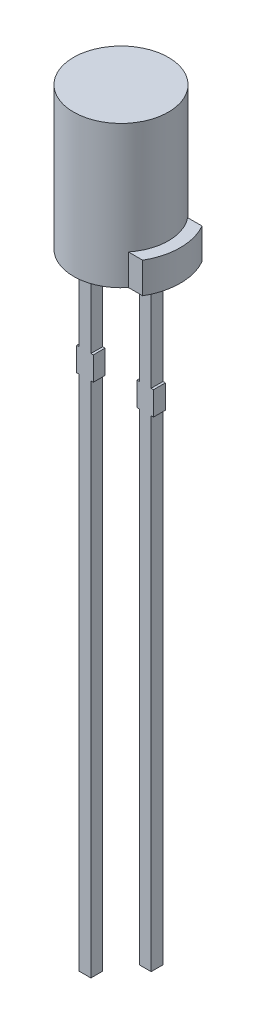
from build123d import *

# Parameters (mm, degrees)
SKETCH2_R          = 2
EXTRUDE2_DEPTH     = 6
SKETCH3_W          = 0.5
SKETCH3_H          = 4.2
SKETCH3_H_2        = 1
SKETCH3_H_3        = 21.8
SKETCH3_W_2        = 0.1
SKETCH3_H_4        = 20.3
EXTRUDE4_DEPTH     = 0.25
EXTRUDE5_DEPTH     = 1.3
CUT_EXTRUDE1_DEPTH = 0.01


with BuildPart() as part:
    # Sketch2 → Extrude2 (new body)
    with BuildSketch(Plane(origin=(0, 0, 0), x_dir=(1, 0, 0), z_dir=(0, 1, 0))):
        with Locations(Location((0, 0, 0), (0, 0, 270))):  # turned: the seam where the file's is
            Circle(SKETCH2_R)
    extrude(amount=EXTRUDE2_DEPTH)

    # Sketch3 → Extrude4 (add, symmetric)
    with BuildSketch(Plane.XY):
        with Locations((-1.27, -2.1)):
            Rectangle(SKETCH3_W, SKETCH3_H)
        with Locations((-1.27, -4.7)):
            Rectangle(SKETCH3_W, SKETCH3_H_2)
        with Locations((-1.27, -16.1)):
            Rectangle(SKETCH3_W, SKETCH3_H_3)
        with Locations((-0.97, -4.7)):
            Rectangle(SKETCH3_W_2, SKETCH3_H_2)
        with Locations((-1.57, -4.7)):
            Rectangle(SKETCH3_W_2, SKETCH3_H_2)
        with Locations((1.27, -2.1)):
            Rectangle(SKETCH3_W, SKETCH3_H)
        with Locations((1.27, -4.7)):
            Rectangle(SKETCH3_W, SKETCH3_H_2)
        with Locations((0.97, -4.7)):
            Rectangle(SKETCH3_W_2, SKETCH3_H_2)
        with Locations((1.57, -4.7)):
            Rectangle(SKETCH3_W_2, SKETCH3_H_2)
        with Locations((1.27, -15.35)):
            Rectangle(SKETCH3_W, SKETCH3_H_4)
    extrude(amount=EXTRUDE4_DEPTH, both=True)

    # Sketch2_4 → Extrude5 (add)
    with BuildSketch(Plane(origin=(0, 0, 0), x_dir=(1, 0, 0), z_dir=(0, 1, 0))):
        with BuildLine():
            ThreePointArc((2, 0), (1.887127314, -0.662382443), (1.5612495, -1.25))
            Line((1.5612495, -1.25), (2.165063509, -1.25))
            ThreePointArc((2.165063509, -1.25), (2.414814566, -0.647047613), (2.5, 0))
            ThreePointArc((2.5, 0), (2.414814566, 0.647047613), (2.165063509, 1.25))
            Line((2.165063509, 1.25), (1.5612495, 1.25))
            ThreePointArc((1.5612495, 1.25), (1.887127314, 0.662382443), (2, 0))
        make_face()
    extrude(amount=EXTRUDE5_DEPTH)

    # Sketch4 → Cut-Extrude1 (cut)
    with BuildSketch(Plane.XZ):
        Polygon((0.595738806, 1.083150286), (0.611739597, 1.159594115), (0.636996717, 1.161967533), (0.656874091, 1.113352027), (0.667020452, 1.164815634), (0.692613806, 1.167228609), (0.722459534, 1.095116267), (0.697459534, 1.092742849), (0.679916021, 1.142742849), (0.668879629, 1.090052976), (0.64777599, 1.088055349), (0.627859059, 1.137818008), (0.620204787, 1.08544459), align=None)
        Polygon((0.462167009, 1.070418429), (0.4781678, 1.146862258), (0.503424921, 1.149235676), (0.523302294, 1.10062017), (0.533448655, 1.152083777), (0.559042009, 1.154496752), (0.588887737, 1.08238441), (0.563887737, 1.080010993), (0.546344224, 1.130010993), (0.535307832, 1.077321119), (0.514204193, 1.075323493), (0.494287262, 1.125086151), (0.48663299, 1.072712733), align=None)
        Polygon((0.328595212, 1.057686572), (0.344596004, 1.134130401), (0.369853124, 1.136503819), (0.389730497, 1.087888313), (0.399876858, 1.13935192), (0.425470212, 1.141764895), (0.45531594, 1.069652553), (0.43031594, 1.067279136), (0.412772428, 1.117279136), (0.401736035, 1.064589262), (0.380632396, 1.062591636), (0.360715466, 1.112354294), (0.353061193, 1.059980876), align=None)
        Polygon((0.280862023, 1.127984779), (0.305585124, 1.13031864), (0.308037656, 1.104329716), (0.283314555, 1.101995855), align=None)
        with BuildLine():
            add(Edge.make_bspline(
                [(0.180076069, 1.08718491), (0.180000938, 1.088378037), (0.179853848, 1.090713918), (0.180129363, 1.094174057), (0.180772304, 1.09750651), (0.181856392, 1.100695423), (0.183302133, 1.103767609), (0.18521883, 1.106654646), (0.18748007, 1.109447891), (0.190155899, 1.11206351), (0.193175315, 1.114489277), (0.196515958, 1.116671544), (0.200162875, 1.118590066), (0.204091964, 1.120276489), (0.208348969, 1.121652526), (0.212888675, 1.122790391), (0.21773693, 1.123691997), (0.221080447, 1.12406052), (0.222797588, 1.124249783)],
                knots=[0, 0, 0, 0, 0.905522218, 1.772813168, 2.623814422, 3.472742767, 4.320212635, 5.190997638, 6.093561936, 7.040949947, 8.022337583, 9.026208329, 10.061623486, 11.143404926, 12.264251371, 13.450050967, 14.690414041, 16, 16, 16, 16], degree=3))
            add(Edge.make_bspline(
                [(0.222797588, 1.124249783), (0.224774175, 1.124417215), (0.228604197, 1.124741645), (0.234184017, 1.124846502), (0.239397228, 1.124699269), (0.244272845, 1.124176891), (0.248896938, 1.123460808), (0.253350833, 1.122554062), (0.257690232, 1.12155369), (0.260505957, 1.120711127), (0.261899645, 1.120294087)],
                knots=[0, 0, 0, 0, 1.202486756, 2.330052293, 3.38202457, 4.36253435, 5.30106619, 6.218328595, 7.118133652, 8, 8, 8, 8], degree=3))
            Line((0.261899645, 1.120294087), (0.264134613, 1.096678581))
            Line((0.264134613, 1.096678581), (0.261345847, 1.096401682))
            add(Edge.make_bspline(
                [(0.261345847, 1.096401682), (0.259917289, 1.097292344), (0.257064127, 1.099071203), (0.252499329, 1.101260048), (0.247738834, 1.10306299), (0.242832824, 1.104464353), (0.237909015, 1.105500935), (0.233059022, 1.106084672), (0.228340168, 1.106322757), (0.225249594, 1.106115915), (0.223727177, 1.106014024)],
                knots=[0, 0, 0, 0, 1.021706956, 2.040585956, 3.068229685, 4.109840531, 5.136110676, 6.120371821, 7.074095265, 8, 8, 8, 8], degree=3))
            add(Edge.make_bspline(
                [(0.223727177, 1.106014024), (0.223311342, 1.105971661), (0.222417695, 1.10588062), (0.220995596, 1.105650523), (0.219393538, 1.105373576), (0.217675381, 1.105055478), (0.21595584, 1.104675901), (0.21436053, 1.104231104), (0.212941274, 1.103715034), (0.21207531, 1.103316459), (0.211662303, 1.103126366)],
                knots=[0, 0, 0, 0, 0.804935788, 1.729844701, 2.773683006, 3.936767773, 5.095129051, 6.164379369, 7.124532199, 8, 8, 8, 8], degree=3))
            add(Edge.make_bspline(
                [(0.211662303, 1.103126366), (0.211210087, 1.102875996), (0.210338649, 1.102393524), (0.20912191, 1.101573972), (0.208071232, 1.100661203), (0.207113032, 1.09972013), (0.206334268, 1.098631764), (0.205896122, 1.097315735), (0.205670284, 1.095828554), (0.205734399, 1.094780476), (0.205768316, 1.094226049)],
                knots=[0, 0, 0, 0, 1.078489755, 2.078289828, 3.054234947, 3.978481303, 4.879078298, 5.81472297, 6.844001073, 8, 8, 8, 8], degree=3))
            add(Edge.make_bspline(
                [(0.205768316, 1.094226049), (0.20584868, 1.093704947), (0.206008065, 1.092671446), (0.206698321, 1.091229038), (0.207715875, 1.089948872), (0.209043641, 1.088802023), (0.210715637, 1.08786966), (0.212676562, 1.087080135), (0.214938325, 1.086447473), (0.216563904, 1.086191829), (0.217417841, 1.086057537)],
                knots=[0, 0, 0, 0, 0.819272605, 1.624862559, 2.460512002, 3.357803212, 4.344338068, 5.433444579, 6.651754585, 8, 8, 8, 8], degree=3))
            add(Edge.make_bspline(
                [(0.217417841, 1.086057537), (0.219361274, 1.085793675), (0.223340984, 1.085253345), (0.229382481, 1.084690325), (0.23541753, 1.084026649), (0.239350214, 1.08322508), (0.241270689, 1.082833644)],
                knots=[0, 0, 0, 0, 0.977169242, 2.001022012, 3.023825344, 4, 4, 4, 4], degree=3))
            add(Edge.make_bspline(
                [(0.241270689, 1.082833644), (0.242308421, 1.082586798), (0.244324322, 1.082107275), (0.247219826, 1.081238479), (0.249902679, 1.08024935), (0.252373636, 1.079144719), (0.254645691, 1.077936669), (0.256710312, 1.076616114), (0.258555413, 1.075169128), (0.260196383, 1.073611153), (0.261647083, 1.07193739), (0.262938308, 1.070150628), (0.264069747, 1.068243844), (0.265038785, 1.066217551), (0.265858503, 1.06407731), (0.266477786, 1.061801155), (0.266988538, 1.059419702), (0.267168428, 1.057776531), (0.267259613, 1.056943613)],
                knots=[0, 0, 0, 0, 1.286961518, 2.500053848, 3.645331982, 4.734993694, 5.763585052, 6.747778267, 7.688337644, 8.588673112, 9.474016412, 10.357212555, 11.245410657, 12.145640677, 13.064656499, 14.006627877, 14.989566337, 16, 16, 16, 16], degree=3))
            add(Edge.make_bspline(
                [(0.267259613, 1.056943613), (0.267324594, 1.055816697), (0.267452431, 1.053599709), (0.267204619, 1.050309014), (0.266483677, 1.047154778), (0.265430191, 1.044103412), (0.263911642, 1.041204275), (0.262045189, 1.038398113), (0.259721017, 1.035761505), (0.25706498, 1.033230857), (0.254061639, 1.030921484), (0.250812211, 1.028814776), (0.247310428, 1.026969486), (0.243557681, 1.025385406), (0.239550974, 1.024071042), (0.235310655, 1.022981477), (0.230822796, 1.022147227), (0.227738257, 1.021797961), (0.22615993, 1.021619245)],
                knots=[0, 0, 0, 0, 0.896646048, 1.763978263, 2.612019967, 3.462260768, 4.322391784, 5.206065637, 6.134830007, 7.109712514, 8.118089394, 9.141388381, 10.184527878, 11.260019642, 12.375272374, 13.533145802, 14.737735533, 16, 16, 16, 16], degree=3))
            add(Edge.make_bspline(
                [(0.22615993, 1.021619245), (0.224545593, 1.021489847), (0.221320456, 1.021231333), (0.216468108, 1.021154677), (0.211616101, 1.02125482), (0.206819112, 1.021640639), (0.202182402, 1.022209983), (0.197799089, 1.022916349), (0.193719224, 1.023764537), (0.191135007, 1.024505061), (0.189886196, 1.024862916)],
                knots=[0, 0, 0, 0, 1.060995351, 2.119666118, 3.178433844, 4.240062289, 5.271587711, 6.238937603, 7.148974324, 8, 8, 8, 8], degree=3))
            Line((0.189886196, 1.024862916), (0.18775012, 1.047548834))
            Line((0.18775012, 1.047548834), (0.190459771, 1.047805954))
            add(Edge.make_bspline(
                [(0.190459771, 1.047805954), (0.191568298, 1.047117926), (0.193832759, 1.045712444), (0.197541182, 1.043982127), (0.201532726, 1.042423399), (0.20579817, 1.041143403), (0.210228115, 1.040139996), (0.214731312, 1.039579525), (0.219239836, 1.039375158), (0.222231203, 1.039576372), (0.223727177, 1.039676999)],
                knots=[0, 0, 0, 0, 0.897762896, 1.833920623, 2.812788637, 3.846900937, 4.897780298, 5.936764651, 6.968182516, 8, 8, 8, 8], degree=3))
            add(Edge.make_bspline(
                [(0.223727177, 1.039676999), (0.224777359, 1.039802953), (0.226881861, 1.040055357), (0.229997825, 1.040658599), (0.233051122, 1.041528956), (0.234946046, 1.042444406), (0.235890942, 1.042900891)],
                knots=[0, 0, 0, 0, 1.002284203, 2.008515686, 3.006954358, 4, 4, 4, 4], degree=3))
            add(Edge.make_bspline(
                [(0.235890942, 1.042900891), (0.23629072, 1.043117546), (0.237089435, 1.043550401), (0.238206516, 1.044330643), (0.239166674, 1.045290227), (0.240070589, 1.046291219), (0.240772178, 1.047416056), (0.241296483, 1.048587502), (0.24151249, 1.049835654), (0.241483302, 1.050666905), (0.241468474, 1.051089182)],
                knots=[0, 0, 0, 0, 1.037193998, 2.072204887, 3.093354871, 4.127600583, 5.141526014, 6.105240849, 7.037459425, 8, 8, 8, 8], degree=3))
            add(Edge.make_bspline(
                [(0.241468474, 1.051089182), (0.241380153, 1.051703821), (0.241210038, 1.052887671), (0.24046405, 1.054494124), (0.239391399, 1.055857771), (0.238169782, 1.056704923), (0.237016987, 1.057274584), (0.235971869, 1.057685858), (0.234758403, 1.058053507), (0.233392041, 1.058407021), (0.231863692, 1.058749275), (0.230164681, 1.059032004), (0.228300648, 1.059319217), (0.22699791, 1.059460746), (0.226318158, 1.059534594)],
                knots=[0, 0, 0, 0, 1.171426997, 2.25627642, 3.314014895, 4.423837728, 5.038558498, 5.750938772, 6.549313359, 7.440391281, 8.425752722, 9.516630727, 10.704208796, 12, 12, 12, 12], degree=3))
            add(Edge.make_bspline(
                [(0.226318158, 1.059534594), (0.224512168, 1.059743208), (0.220973241, 1.060151999), (0.215652889, 1.060692407), (0.210229219, 1.061455286), (0.206581538, 1.062233985), (0.204680499, 1.062639815)],
                knots=[0, 0, 0, 0, 0.997345898, 1.954349026, 2.933880906, 4, 4, 4, 4], degree=3))
            add(Edge.make_bspline(
                [(0.204680499, 1.062639815), (0.203735086, 1.06286721), (0.201891253, 1.063310696), (0.19923753, 1.064125651), (0.196759615, 1.06503224), (0.194457787, 1.066037971), (0.192333478, 1.067153691), (0.190364632, 1.068343753), (0.188608139, 1.069683431), (0.186994749, 1.071092835), (0.185574052, 1.072645801), (0.1842916, 1.074309465), (0.183201032, 1.076135528), (0.182260621, 1.078083423), (0.181455584, 1.080164174), (0.180831803, 1.08238369), (0.180351856, 1.084737379), (0.180169136, 1.086358965), (0.180076069, 1.08718491)],
                knots=[0, 0, 0, 0, 1.23764655, 2.413774307, 3.531682084, 4.595210585, 5.608818858, 6.584790941, 7.519772016, 8.417508597, 9.308431962, 10.194757595, 11.087181963, 12.010602069, 12.945809139, 13.923439875, 14.9423162, 16, 16, 16, 16], degree=3))
        make_face()
        with BuildLine():
            Line((0.086271392, 1.109482974), (0.110084683, 1.111737721))
            Line((0.110084683, 1.111737721), (0.110856044, 1.103529651))
            add(Edge.make_bspline(
                [(0.110856044, 1.103529651), (0.111849622, 1.104429509), (0.113767546, 1.106166521), (0.11667667, 1.108517729), (0.119466318, 1.110561117), (0.122183333, 1.112344803), (0.125011892, 1.113825056), (0.128111342, 1.114915407), (0.131491185, 1.115738487), (0.133860768, 1.116021778), (0.135084683, 1.116168101)],
                knots=[0, 0, 0, 0, 1.152164645, 2.224045628, 3.213659577, 4.123879723, 5.016101453, 5.950129621, 6.941219263, 8, 8, 8, 8], degree=3))
            add(Edge.make_bspline(
                [(0.135084683, 1.116168101), (0.136086192, 1.116246892), (0.138028632, 1.116399708), (0.140880931, 1.116302044), (0.143576357, 1.116020267), (0.146125992, 1.115491624), (0.148514198, 1.114697319), (0.150740579, 1.113653476), (0.152840016, 1.11241954), (0.154737082, 1.110890425), (0.156497127, 1.109173054), (0.158042647, 1.107188703), (0.15941065, 1.104988595), (0.160576651, 1.102550543), (0.161570406, 1.099891588), (0.162343791, 1.096994045), (0.16297248, 1.093877457), (0.163207296, 1.091711281), (0.163328354, 1.090594525)],
                knots=[0, 0, 0, 0, 1.108114918, 2.149202164, 3.14494175, 4.096957924, 5.01749491, 5.91613894, 6.807266765, 7.698335156, 8.598892543, 9.516115384, 10.467268884, 11.453495497, 12.494353796, 13.596021602, 14.76064642, 16, 16, 16, 16], degree=3))
            Line((0.163328354, 1.090594525), (0.167897183, 1.042255917))
            Line((0.167897183, 1.042255917), (0.143945443, 1.04000117))
            Line((0.143945443, 1.04000117), (0.14046443, 1.076828702))
            add(Edge.make_bspline(
                [(0.14046443, 1.076828702), (0.140374833, 1.077725591), (0.140203381, 1.079441862), (0.139915149, 1.081897121), (0.139575212, 1.084105018), (0.139228687, 1.086088659), (0.138811258, 1.087866475), (0.13833112, 1.089476396), (0.137724474, 1.090913223), (0.137210636, 1.091766596), (0.136963639, 1.092176803)],
                knots=[0, 0, 0, 0, 1.362599764, 2.607448668, 3.736476168, 4.739330694, 5.650702323, 6.495560924, 7.276831317, 8, 8, 8, 8], degree=3))
            add(Edge.make_bspline(
                [(0.136963639, 1.092176803), (0.136696476, 1.092540527), (0.136169677, 1.093257726), (0.13520928, 1.094198473), (0.13406344, 1.094897705), (0.132782392, 1.095455571), (0.131303082, 1.095799624), (0.129605328, 1.095986883), (0.127671488, 1.096027069), (0.126309056, 1.09591478), (0.125591012, 1.095855601)],
                knots=[0, 0, 0, 0, 0.856644385, 1.689153085, 2.533351611, 3.391641808, 4.333134902, 5.404855211, 6.632277889, 8, 8, 8, 8], degree=3))
            add(Edge.make_bspline(
                [(0.125591012, 1.095855601), (0.125068378, 1.095793375), (0.123994211, 1.095665484), (0.12236668, 1.095265521), (0.12066363, 1.094760329), (0.118313678, 1.093845691), (0.115353605, 1.09243765), (0.11320849, 1.09089917), (0.112121867, 1.090119841)],
                knots=[0, 0, 0, 0, 0.639166514, 1.313674521, 2.03363351, 2.797097134, 4.377547342, 6, 6, 6, 6], degree=3))
            Line((0.112121867, 1.090119841), (0.117106044, 1.037469525))
            Line((0.117106044, 1.037469525), (0.093292753, 1.035214778))
            Line((0.093292753, 1.035214778), (0.086271392, 1.109482974))
        make_face()
        with BuildLine():
            Line((-0.011350532, 1.100175026), (0.01258143, 1.102429773))
            Line((0.01258143, 1.102429773), (0.016062443, 1.065602241))
            add(Edge.make_bspline(
                [(0.016062443, 1.065602241), (0.016224024, 1.064103453), (0.016546316, 1.061113945), (0.017185987, 1.057457291), (0.017794896, 1.05470606), (0.018328449, 1.052950313), (0.018882429, 1.051471907), (0.019362029, 1.050638258), (0.019583013, 1.05025414)],
                knots=[0, 0, 0, 0, 1.711554294, 3.413896861, 4.213021049, 4.90936265, 5.497470356, 6, 6, 6, 6], degree=3))
            add(Edge.make_bspline(
                [(0.019583013, 1.05025414), (0.019855509, 1.049888664), (0.020396209, 1.049163471), (0.021392697, 1.048251912), (0.022528125, 1.047519741), (0.023820337, 1.046983003), (0.025300702, 1.046623817), (0.027002585, 1.046472656), (0.028934142, 1.046421008), (0.030296807, 1.046535029), (0.031014975, 1.046595121)],
                knots=[0, 0, 0, 0, 0.861634224, 1.709689945, 2.540671462, 3.407713485, 4.346206362, 5.41312505, 6.636636352, 8, 8, 8, 8], degree=3))
            add(Edge.make_bspline(
                [(0.031014975, 1.046595121), (0.03210339, 1.046753268), (0.034322261, 1.047075672), (0.037026563, 1.048008434), (0.039195133, 1.04902622), (0.040884187, 1.049990206), (0.042657828, 1.051064798), (0.043810812, 1.051900301), (0.044405006, 1.05233088)],
                knots=[0, 0, 0, 0, 1.340233279, 2.732231585, 3.470218484, 4.262786462, 5.104721098, 6, 6, 6, 6], degree=3))
            Line((0.044405006, 1.05233088), (0.039440607, 1.104981197))
            Line((0.039440607, 1.104981197), (0.063253899, 1.107216165))
            Line((0.063253899, 1.107216165), (0.070275259, 1.032947969))
            Line((0.070275259, 1.032947969), (0.046461968, 1.030713001))
            Line((0.046461968, 1.030713001), (0.045690607, 1.03892107))
            add(Edge.make_bspline(
                [(0.045690607, 1.03892107), (0.044722801, 1.038035385), (0.042838874, 1.036311314), (0.039958292, 1.033942193), (0.037077509, 1.031917839), (0.034253361, 1.030104467), (0.031319652, 1.028628499), (0.028212176, 1.027504893), (0.024911204, 1.026677811), (0.022626515, 1.026402946), (0.021461968, 1.026262842)],
                knots=[0, 0, 0, 0, 1.128280691, 2.196305633, 3.204826773, 4.155092717, 5.080676663, 6.022445781, 6.992005032, 8, 8, 8, 8], degree=3))
            add(Edge.make_bspline(
                [(0.021461968, 1.026262842), (0.02048028, 1.026195666), (0.018570738, 1.026064997), (0.015762651, 1.026113586), (0.013103429, 1.026439647), (0.01058162, 1.026960838), (0.008206562, 1.027737477), (0.005983167, 1.02875503), (0.003882723, 1.029984284), (0.001941321, 1.031470597), (0.000178933, 1.033205442), (-0.001426435, 1.035155596), (-0.002799843, 1.037365119), (-0.004001568, 1.039800062), (-0.004971709, 1.042479431), (-0.005792132, 1.045385243), (-0.006396241, 1.048529928), (-0.006650817, 1.05071368), (-0.006781703, 1.051836418)],
                knots=[0, 0, 0, 0, 1.0872505, 2.114877859, 3.098202874, 4.044268561, 4.956739394, 5.853451236, 6.741954745, 7.641149904, 8.54801769, 9.469808848, 10.426006009, 11.41664689, 12.465622852, 13.570601432, 14.750967542, 16, 16, 16, 16], degree=3))
            Line((-0.006781703, 1.051836418), (-0.011350532, 1.100175026))
        make_face()
        Polygon((-0.106144133, 1.091143976), (-0.035099829, 1.097848881), (-0.025803943, 0.999371824), (-0.051199513, 0.996978628), (-0.058695557, 1.076409008), (-0.104344291, 1.072097299), align=None)
        Polygon((-0.193289597, 1.082836479), (-0.122047508, 1.089561163), (-0.112751622, 0.991084106), (-0.183993711, 0.984359423), (-0.185793552, 1.0034061), (-0.139828362, 1.007737587), (-0.141430419, 1.024727302), (-0.184072824, 1.020712271), (-0.185872666, 1.039758948), (-0.143230261, 1.043773979), (-0.145524565, 1.06812129), (-0.191489755, 1.063789802), align=None)
        with BuildLine():
            add(Edge.make_bspline(
                [(-0.303705554, 1.022761493), (-0.303792129, 1.023894809), (-0.303963094, 1.026132847), (-0.303972821, 1.029468777), (-0.303806975, 1.032733321), (-0.30340296, 1.035929993), (-0.302811858, 1.039055184), (-0.302025455, 1.042112375), (-0.301005518, 1.045088017), (-0.299804382, 1.047978918), (-0.298442762, 1.050766146), (-0.296937442, 1.053406734), (-0.295335538, 1.055920588), (-0.293593073, 1.058263776), (-0.291753775, 1.06047237), (-0.289783343, 1.062519998), (-0.287690839, 1.064418614), (-0.286208868, 1.065577522), (-0.285469794, 1.066155481)],
                knots=[0, 0, 0, 0, 1.108752944, 2.189532157, 3.252570796, 4.296260022, 5.330849015, 6.354419021, 7.373633347, 8.397486336, 9.407338928, 10.398369786, 11.361982234, 12.314102121, 13.245680119, 14.164735136, 15.084735289, 16, 16, 16, 16], degree=3))
            add(Edge.make_bspline(
                [(-0.285469794, 1.066155481), (-0.2843176, 1.06696977), (-0.282007793, 1.068602178), (-0.278268378, 1.07063659), (-0.274352835, 1.072400327), (-0.270180231, 1.073821532), (-0.265704801, 1.075014233), (-0.260844852, 1.075978994), (-0.255582699, 1.076827322), (-0.251921345, 1.0771979), (-0.250026756, 1.077389658)],
                knots=[0, 0, 0, 0, 0.898226624, 1.800676254, 2.706959409, 3.631504289, 4.605561171, 5.655869771, 6.787016565, 8, 8, 8, 8], degree=3))
            Line((-0.250026756, 1.077389658), (-0.215295744, 1.080672886))
            Line((-0.215295744, 1.080672886), (-0.205999857, 0.982195829))
            Line((-0.205999857, 0.982195829), (-0.241719794, 0.978813708))
            add(Edge.make_bspline(
                [(-0.241719794, 0.978813708), (-0.243663561, 0.978657033), (-0.247408755, 0.978355154), (-0.252855343, 0.978211823), (-0.257908459, 0.978355789), (-0.262588096, 0.978802824), (-0.266892165, 0.979544215), (-0.270871126, 0.980480265), (-0.27453305, 0.98166909), (-0.276795456, 0.982702469), (-0.277894636, 0.983204531)],
                knots=[0, 0, 0, 0, 1.268673849, 2.444444452, 3.543152422, 4.556056618, 5.500363377, 6.382673113, 7.214228933, 8, 8, 8, 8], degree=3))
            add(Edge.make_bspline(
                [(-0.277894636, 0.983204531), (-0.278778193, 0.983653836), (-0.280537922, 0.98454869), (-0.283043061, 0.986099536), (-0.285433159, 0.98779185), (-0.287703789, 0.989623553), (-0.289844191, 0.991612703), (-0.291872437, 0.993733605), (-0.293771489, 0.996015954), (-0.295552346, 0.998440178), (-0.297173431, 1.001020091), (-0.298642889, 1.003721848), (-0.299906373, 1.006572259), (-0.301014752, 1.009544723), (-0.301968088, 1.01265352), (-0.302734447, 1.015904619), (-0.303334277, 1.019285587), (-0.303580714, 1.021592739), (-0.303705554, 1.022761493)],
                knots=[0, 0, 0, 0, 0.961009519, 1.913987343, 2.854267442, 3.799945452, 4.741073053, 5.686297007, 6.644153152, 7.618681425, 8.601460506, 9.597072869, 10.598825991, 11.622600514, 12.672342922, 13.750217676, 14.860307228, 16, 16, 16, 16], degree=3))
        make_face()
        with BuildLine():
            add(Edge.make_bspline(
                [(-0.277439731, 1.025036019), (-0.277259987, 1.023473422), (-0.276912118, 1.020449237), (-0.275786631, 1.016154582), (-0.274356666, 1.012218874), (-0.272744075, 1.009262645), (-0.271252181, 1.007121952), (-0.270019286, 1.005636341), (-0.268676983, 1.004238569), (-0.267182073, 1.002984642), (-0.265592739, 1.0018004), (-0.263875219, 1.000743418), (-0.262040313, 0.99977832), (-0.260751229, 0.999241614), (-0.260094003, 0.998967981)],
                knots=[0, 0, 0, 0, 1.705404723, 3.300570454, 4.806618999, 6.241382947, 6.940248714, 7.636655035, 8.335080941, 9.040693201, 9.752088672, 10.484904539, 11.227544252, 12, 12, 12, 12], degree=3))
            add(Edge.make_bspline(
                [(-0.260094003, 0.998967981), (-0.258739814, 0.998520176), (-0.256066773, 0.997636253), (-0.252503261, 0.997091439), (-0.249400572, 0.997005927), (-0.246570281, 0.99708308), (-0.243232206, 0.997256616), (-0.240842341, 0.997469571), (-0.23956394, 0.997583487)],
                knots=[0, 0, 0, 0, 1.234151206, 2.436098757, 3.104722821, 3.921632553, 4.888226682, 6, 6, 6, 6], degree=3))
            Line((-0.23956394, 0.997583487), (-0.233135933, 0.99819662))
            Line((-0.233135933, 0.99819662), (-0.238950807, 1.059826367))
            Line((-0.238950807, 1.059826367), (-0.245378813, 1.059213234))
            add(Edge.make_bspline(
                [(-0.245378813, 1.059213234), (-0.24611101, 1.059144328), (-0.247517373, 1.059011977), (-0.249552496, 1.058761781), (-0.251434172, 1.058537835), (-0.253168361, 1.05827812), (-0.254736755, 1.058001756), (-0.256162814, 1.05772579), (-0.257428978, 1.057433769), (-0.258923036, 1.057037555), (-0.260667701, 1.056450563), (-0.26268502, 1.055571273), (-0.264672367, 1.05454721), (-0.265940938, 1.053744336), (-0.266581345, 1.053339025)],
                knots=[0, 0, 0, 0, 1.189098597, 2.283956679, 3.31531765, 4.253067775, 5.118858824, 5.890319965, 6.601456144, 7.21948254, 8.389262148, 9.573476576, 10.775029794, 12, 12, 12, 12], degree=3))
            add(Edge.make_bspline(
                [(-0.266581345, 1.053339025), (-0.267116183, 1.052952686), (-0.268170255, 1.052191281), (-0.269606691, 1.050901401), (-0.270973292, 1.049590859), (-0.272166574, 1.048154483), (-0.273264618, 1.046677409), (-0.274219642, 1.045110126), (-0.275070532, 1.043482574), (-0.276030696, 1.041168033), (-0.276950919, 1.038054106), (-0.277563435, 1.034011903), (-0.27776383, 1.029628426), (-0.277550407, 1.02660428), (-0.277439731, 1.025036019)],
                knots=[0, 0, 0, 0, 0.742914295, 1.464153614, 2.173354713, 2.874415501, 3.565365736, 4.245771409, 4.94022741, 5.632853065, 7.0666969, 8.586097399, 10.229617933, 12, 12, 12, 12], degree=3))
        make_face(mode=Mode.SUBTRACT)
        Polygon((-0.352973956, 1.067568515), (-0.328250855, 1.069902375), (-0.325798323, 1.043913451), (-0.350521424, 1.041579591), align=None)
        with BuildLine():
            add(Edge.make_bspline(
                [(-0.415409435, 1.063615956), (-0.413821645, 1.063743708), (-0.410708716, 1.06399417), (-0.406107699, 1.063984904), (-0.401691325, 1.063678512), (-0.397463956, 1.063048312), (-0.393445018, 1.062104384), (-0.389632506, 1.060843053), (-0.386061328, 1.059211003), (-0.383862792, 1.057844384), (-0.382774942, 1.057168171)],
                knots=[0, 0, 0, 0, 1.12675004, 2.209039731, 3.2520183, 4.256823248, 5.229940226, 6.169653809, 7.094332871, 8, 8, 8, 8], degree=3))
            add(Edge.make_bspline(
                [(-0.382774942, 1.057168171), (-0.381746646, 1.056420894), (-0.379691413, 1.054927327), (-0.376949317, 1.052242825), (-0.374528801, 1.049211341), (-0.372402954, 1.045853971), (-0.370603816, 1.042145694), (-0.369218376, 1.038070867), (-0.368172328, 1.033652714), (-0.367810844, 1.030571252), (-0.367624625, 1.028983836)],
                knots=[0, 0, 0, 0, 0.920615294, 1.840013812, 2.771606673, 3.727671218, 4.715306354, 5.752253409, 6.842072703, 8, 8, 8, 8], degree=3))
            add(Edge.make_bspline(
                [(-0.367624625, 1.028983836), (-0.367503718, 1.027303468), (-0.367269989, 1.02405512), (-0.367504426, 1.019309096), (-0.368150074, 1.014871622), (-0.369313023, 1.010747488), (-0.370882652, 1.006929088), (-0.372829179, 1.00339764), (-0.375171847, 1.00016223), (-0.37700921, 0.998254132), (-0.377929214, 0.997298709)],
                knots=[0, 0, 0, 0, 1.170245432, 2.262222357, 3.296097347, 4.281367261, 5.232928986, 6.160206927, 7.078779014, 8, 8, 8, 8], degree=3))
            add(Edge.make_bspline(
                [(-0.377929214, 0.997298709), (-0.378881455, 0.996453535), (-0.380798741, 0.994751823), (-0.384007463, 0.992567023), (-0.387467862, 0.990662357), (-0.391158068, 0.989047666), (-0.395032097, 0.98774392), (-0.399018604, 0.986664051), (-0.403112001, 0.985870922), (-0.405886857, 0.985552158), (-0.40728048, 0.985392064)],
                knots=[0, 0, 0, 0, 0.946906943, 1.90654564, 2.88174188, 3.883744891, 4.900207498, 5.921538793, 6.956129209, 8, 8, 8, 8], degree=3))
            add(Edge.make_bspline(
                [(-0.40728048, 0.985392064), (-0.408525798, 0.98530021), (-0.410967975, 0.985120078), (-0.414581695, 0.985071194), (-0.418068467, 0.985278659), (-0.421438341, 0.985665753), (-0.424682581, 0.986269648), (-0.427824505, 0.987016797), (-0.430887767, 0.987836636), (-0.43286488, 0.988543273), (-0.43384298, 0.988892855)],
                knots=[0, 0, 0, 0, 1.10896075, 2.174767254, 3.207037272, 4.209376132, 5.185650549, 6.135885339, 7.077802142, 8, 8, 8, 8], degree=3))
            Line((-0.43384298, 0.988892855), (-0.435761492, 1.009205355))
            Line((-0.435761492, 1.009205355), (-0.432379372, 1.00952181))
            add(Edge.make_bspline(
                [(-0.432379372, 1.00952181), (-0.431824967, 1.009140287), (-0.430625807, 1.008315064), (-0.428702697, 1.006962659), (-0.426384606, 1.005573976), (-0.424629948, 1.004807098), (-0.423696619, 1.004399184)],
                knots=[0, 0, 0, 0, 0.799084726, 1.728394909, 2.791698194, 4, 4, 4, 4], degree=3))
            add(Edge.make_bspline(
                [(-0.423696619, 1.004399184), (-0.422713951, 1.004031124), (-0.420700577, 1.003277011), (-0.418037446, 1.002615911), (-0.415759491, 1.00227783), (-0.41390242, 1.00213879), (-0.411932111, 1.002138347), (-0.410582997, 1.002246969), (-0.409891239, 1.002302665)],
                knots=[0, 0, 0, 0, 1.337990229, 2.741389548, 3.489534986, 4.273912528, 5.114950199, 6, 6, 6, 6], degree=3))
            add(Edge.make_bspline(
                [(-0.409891239, 1.002302665), (-0.409117176, 1.002392353), (-0.407616463, 1.002566236), (-0.405463873, 1.00308162), (-0.403449799, 1.003713485), (-0.401609645, 1.004579869), (-0.399899974, 1.005581985), (-0.398380326, 1.006810573), (-0.396977556, 1.008168709), (-0.395771333, 1.009730336), (-0.394730728, 1.011433917), (-0.393827069, 1.01325337), (-0.393144057, 1.015211688), (-0.392611415, 1.01727585), (-0.392224626, 1.019457038), (-0.392067851, 1.021761587), (-0.392034161, 1.024180657), (-0.392163019, 1.025826364), (-0.392229056, 1.026669753)],
                knots=[0, 0, 0, 0, 1.094995874, 2.122921033, 3.108179543, 4.058251519, 4.977412549, 5.888304534, 6.799715531, 7.717893827, 8.654613687, 9.604278324, 10.56921186, 11.565534943, 12.600628658, 13.679487035, 14.81078666, 16, 16, 16, 16], degree=3))
            add(Edge.make_bspline(
                [(-0.392229056, 1.026669753), (-0.392329192, 1.027535187), (-0.392523581, 1.029215213), (-0.393003494, 1.031633699), (-0.393606646, 1.033881051), (-0.394378552, 1.035948814), (-0.395307529, 1.037841167), (-0.396400799, 1.039548882), (-0.39763151, 1.041083687), (-0.399004238, 1.042439637), (-0.400515404, 1.043608259), (-0.402151243, 1.044608995), (-0.403911094, 1.045415873), (-0.405793675, 1.046039487), (-0.407793583, 1.046442388), (-0.409910872, 1.046678228), (-0.412148517, 1.046745437), (-0.413676033, 1.04662746), (-0.414460068, 1.046566905)],
                knots=[0, 0, 0, 0, 1.228965952, 2.385735588, 3.475863361, 4.50921211, 5.495285741, 6.445008473, 7.364729435, 8.266008481, 9.16112025, 10.054635116, 10.966274306, 11.887123876, 12.846864245, 13.839324827, 14.89098052, 16, 16, 16, 16], degree=3))
            add(Edge.make_bspline(
                [(-0.414460068, 1.046566905), (-0.41518619, 1.046481576), (-0.416611046, 1.046314134), (-0.418684421, 1.045950642), (-0.420633733, 1.045432943), (-0.42244139, 1.044792902), (-0.424116188, 1.044114745), (-0.425624299, 1.043367541), (-0.427000698, 1.042634455), (-0.427828085, 1.042071135), (-0.428225891, 1.041800291)],
                knots=[0, 0, 0, 0, 1.191442946, 2.337950479, 3.427351757, 4.47394677, 5.461634542, 6.369857425, 7.216231234, 8, 8, 8, 8], degree=3))
            add(Edge.make_bspline(
                [(-0.428225891, 1.041800291), (-0.428902417, 1.041292297), (-0.430206104, 1.040313376), (-0.431920334, 1.038690404), (-0.433430278, 1.037087289), (-0.434372785, 1.036027153), (-0.434831904, 1.035510735)],
                knots=[0, 0, 0, 0, 1.109595254, 2.138223272, 3.093083025, 4, 4, 4, 4], degree=3))
            Line((-0.434831904, 1.035510735), (-0.438214024, 1.035194279))
            Line((-0.438214024, 1.035194279), (-0.440132537, 1.055487))
            add(Edge.make_bspline(
                [(-0.440132537, 1.055487), (-0.439234147, 1.056003423), (-0.437428192, 1.057041541), (-0.434630675, 1.058439562), (-0.431744858, 1.059681032), (-0.42878687, 1.060830757), (-0.425681131, 1.061798658), (-0.422421927, 1.062613448), (-0.418978408, 1.06322962), (-0.416617804, 1.063485152), (-0.415409435, 1.063615956)],
                knots=[0, 0, 0, 0, 0.947330783, 1.904335564, 2.857326213, 3.81897093, 4.804630844, 5.829491346, 6.888939505, 8, 8, 8, 8], degree=3))
        make_face()
        with BuildLine():
            add(Edge.make_bspline(
                [(-0.529600862, 1.013345728), (-0.529714174, 1.014834831), (-0.529935648, 1.017745347), (-0.529796706, 1.022020984), (-0.529355075, 1.026093055), (-0.528550095, 1.029951723), (-0.527380947, 1.033609894), (-0.525826463, 1.037038312), (-0.523942168, 1.040268924), (-0.521693472, 1.043262679), (-0.5191301, 1.046011958), (-0.516240559, 1.048468407), (-0.513024654, 1.05058149), (-0.509539205, 1.052427683), (-0.505748685, 1.053959183), (-0.501651016, 1.055152086), (-0.497259165, 1.056068777), (-0.494214199, 1.056420912), (-0.492654659, 1.056601266)],
                knots=[0, 0, 0, 0, 1.11005242, 2.169645169, 3.176323611, 4.153438899, 5.096288594, 6.026855042, 6.947758942, 7.872584178, 8.805834089, 9.738220459, 10.686157051, 11.662275176, 12.667567271, 13.721072089, 14.832802022, 16, 16, 16, 16], degree=3))
            add(Edge.make_bspline(
                [(-0.492654659, 1.056601266), (-0.491086559, 1.056718863), (-0.48803176, 1.056947953), (-0.483545464, 1.056861727), (-0.479295929, 1.056437156), (-0.475279057, 1.055651718), (-0.471505218, 1.054496497), (-0.467954944, 1.053024369), (-0.46466722, 1.051138101), (-0.461628044, 1.048924658), (-0.458841121, 1.046411444), (-0.456385574, 1.043586356), (-0.454234089, 1.04049446), (-0.45238672, 1.037135579), (-0.450862174, 1.033494259), (-0.449663916, 1.029584055), (-0.448762922, 1.025401058), (-0.4484254, 1.022506899), (-0.448251969, 1.021019778)],
                knots=[0, 0, 0, 0, 1.168859581, 2.277043282, 3.331750654, 4.34132596, 5.315274156, 6.262256999, 7.193266664, 8.126841649, 9.053555677, 9.977815379, 10.904010515, 11.849736107, 12.823116512, 13.83419064, 14.887130329, 16, 16, 16, 16], degree=3))
            add(Edge.make_bspline(
                [(-0.448251969, 1.021019778), (-0.448141542, 1.019517605), (-0.447926156, 1.016587673), (-0.448023992, 1.012276959), (-0.448500506, 1.008194133), (-0.449304759, 1.004313462), (-0.450489815, 1.000651851), (-0.452042216, 0.997202624), (-0.453953051, 0.993978511), (-0.456212933, 0.99098465), (-0.45880084, 0.988257641), (-0.461703918, 0.98582275), (-0.46488601, 0.983679914), (-0.468393995, 0.981878637), (-0.472171469, 0.980352195), (-0.476254864, 0.979156389), (-0.480619423, 0.978235153), (-0.483645107, 0.97788476), (-0.485198172, 0.977704905)],
                knots=[0, 0, 0, 0, 1.118991295, 2.182551428, 3.198757718, 4.170334766, 5.123298841, 6.053157011, 6.975848312, 7.90291372, 8.835247321, 9.763761876, 10.713697856, 11.680183376, 12.689253149, 13.737258797, 14.838548396, 16, 16, 16, 16], degree=3))
            add(Edge.make_bspline(
                [(-0.485198172, 0.977704905), (-0.486779543, 0.977586518), (-0.489854321, 0.97735633), (-0.494365119, 0.977452371), (-0.498631163, 0.977840343), (-0.502651935, 0.978638298), (-0.506431969, 0.9797838), (-0.509971887, 0.981287212), (-0.513261807, 0.983161971), (-0.516291101, 0.985381865), (-0.519045909, 0.987915104), (-0.521492604, 0.990747522), (-0.523636085, 0.993843137), (-0.525467708, 0.997220005), (-0.526987367, 1.000865908), (-0.52818934, 1.004781315), (-0.529089794, 1.008964485), (-0.529427392, 1.011858619), (-0.529600862, 1.013345728)],
                knots=[0, 0, 0, 0, 1.177198867, 2.288915789, 3.346710114, 4.355043989, 5.327794562, 6.275525004, 7.205389846, 8.133861206, 9.059124775, 9.979034548, 10.908112587, 11.850324255, 12.82702299, 13.836853844, 14.888498778, 16, 16, 16, 16], degree=3))
        make_face()
        with BuildLine():
            add(Edge.make_bspline(
                [(-0.502009881, 1.034172468), (-0.502340006, 1.033645841), (-0.503004418, 1.032585947), (-0.503763847, 1.030833757), (-0.504402745, 1.028971359), (-0.50488848, 1.026933623), (-0.505179222, 1.024641333), (-0.505289043, 1.022022425), (-0.505191832, 1.01903138), (-0.505025352, 1.016918404), (-0.504937096, 1.015798259)],
                knots=[0, 0, 0, 0, 0.784446978, 1.57878649, 2.406085838, 3.271000313, 4.22072047, 5.321616597, 6.580117396, 8, 8, 8, 8], degree=3))
            add(Edge.make_bspline(
                [(-0.504937096, 1.015798259), (-0.504822773, 1.014755145), (-0.504602747, 1.012747568), (-0.504112084, 1.009887077), (-0.503505497, 1.007301209), (-0.50277466, 1.004992502), (-0.501931565, 1.002933562), (-0.500943149, 1.001140909), (-0.499942009, 0.999518476), (-0.499122848, 0.998613387), (-0.498726653, 0.998175633)],
                knots=[0, 0, 0, 0, 1.324165778, 2.548490398, 3.660530677, 4.673660229, 5.602395194, 6.46238622, 7.256319043, 8, 8, 8, 8], degree=3))
            add(Edge.make_bspline(
                [(-0.498726653, 0.998175633), (-0.498327932, 0.997781791), (-0.497542138, 0.997005613), (-0.496207476, 0.996055422), (-0.494787666, 0.995314855), (-0.493288077, 0.994779785), (-0.4917192, 0.994427362), (-0.490102129, 0.994239947), (-0.488440354, 0.994166053), (-0.487327344, 0.994254181), (-0.486760672, 0.99429905)],
                knots=[0, 0, 0, 0, 1.029206098, 2.028344771, 2.99890832, 3.965222977, 4.947451015, 5.948866888, 6.955697837, 8, 8, 8, 8], degree=3))
            add(Edge.make_bspline(
                [(-0.486760672, 0.99429905), (-0.486205824, 0.994364004), (-0.485123066, 0.994490758), (-0.4835523, 0.994803527), (-0.482092937, 0.99524251), (-0.480711319, 0.995769564), (-0.479419857, 0.996502526), (-0.478183789, 0.997440118), (-0.477013779, 0.99861782), (-0.476320624, 0.999525264), (-0.475961621, 0.999995253)],
                knots=[0, 0, 0, 0, 1.058964726, 2.06651437, 3.031527341, 3.946079843, 4.863957847, 5.836470718, 6.879453238, 8, 8, 8, 8], degree=3))
            add(Edge.make_bspline(
                [(-0.475961621, 0.999995253), (-0.47564447, 1.000488701), (-0.474983686, 1.001516799), (-0.474233848, 1.003277564), (-0.473598606, 1.00524991), (-0.473106697, 1.007460582), (-0.472775887, 1.00992106), (-0.472622046, 1.012651372), (-0.472670301, 1.015650722), (-0.472831661, 1.017737224), (-0.472915735, 1.018824367)],
                knots=[0, 0, 0, 0, 0.723215566, 1.506820097, 2.353829399, 3.280108847, 4.299027297, 5.416235151, 6.653764212, 8, 8, 8, 8], degree=3))
            add(Edge.make_bspline(
                [(-0.472915735, 1.018824367), (-0.473027296, 1.019800879), (-0.473243543, 1.021693731), (-0.473673016, 1.024423825), (-0.474307101, 1.026925479), (-0.475002237, 1.029225921), (-0.475827422, 1.031298306), (-0.476759377, 1.033147749), (-0.477816942, 1.03476097), (-0.478646674, 1.03568476), (-0.479047064, 1.036130538)],
                knots=[0, 0, 0, 0, 1.262485239, 2.447175486, 3.545949731, 4.574443268, 5.532065916, 6.406887258, 7.231237093, 8, 8, 8, 8], degree=3))
            add(Edge.make_bspline(
                [(-0.479047064, 1.036130538), (-0.479448678, 1.036501217), (-0.480242918, 1.037234279), (-0.481547393, 1.038182645), (-0.48297639, 1.038883099), (-0.484463006, 1.039451781), (-0.486048578, 1.039814815), (-0.487714419, 1.040063048), (-0.489478778, 1.040116023), (-0.490677267, 1.040030872), (-0.491289944, 1.039987341)],
                knots=[0, 0, 0, 0, 0.986871375, 1.951657744, 2.899542736, 3.85279738, 4.820298672, 5.83066774, 6.891020539, 8, 8, 8, 8], degree=3))
            add(Edge.make_bspline(
                [(-0.491289944, 1.039987341), (-0.491825608, 1.039925086), (-0.492885838, 1.039801864), (-0.494435349, 1.039438835), (-0.495930152, 1.038939102), (-0.497366477, 1.038315396), (-0.498721771, 1.037545044), (-0.499968513, 1.036605474), (-0.501080041, 1.035476941), (-0.501698026, 1.034609969), (-0.502009881, 1.034172468)],
                knots=[0, 0, 0, 0, 1.024910687, 2.028587838, 3.019814089, 4.019174666, 5.002039349, 5.977518795, 6.979393096, 8, 8, 8, 8], degree=3))
        make_face(mode=Mode.SUBTRACT)
        with BuildLine():
            Line((-0.618082483, 0.989208241), (-0.623046882, 1.041858558))
            Line((-0.623046882, 1.041858558), (-0.599095142, 1.044133083))
            Line((-0.599095142, 1.044133083), (-0.59559435, 1.007028653))
            add(Edge.make_bspline(
                [(-0.59559435, 1.007028653), (-0.59551167, 1.006158095), (-0.59535306, 1.004488071), (-0.595075769, 1.002081235), (-0.594774643, 0.999880519), (-0.594492973, 0.997870222), (-0.594146647, 0.996061925), (-0.59370114, 0.994447439), (-0.593127909, 0.993030515), (-0.592655578, 0.992184064), (-0.592429794, 0.991779444)],
                knots=[0, 0, 0, 0, 1.33733818, 2.56546818, 3.704798711, 4.734307723, 5.669598667, 6.518572705, 7.291847407, 8, 8, 8, 8], degree=3))
            add(Edge.make_bspline(
                [(-0.592429794, 0.991779444), (-0.592187633, 0.991417094), (-0.59171104, 0.990703959), (-0.590738835, 0.989862598), (-0.589696695, 0.989123459), (-0.588460455, 0.988607089), (-0.58705474, 0.988255697), (-0.585434059, 0.988062039), (-0.583593025, 0.988060231), (-0.582296135, 0.988151382), (-0.581610964, 0.988199539)],
                knots=[0, 0, 0, 0, 0.862934245, 1.698325216, 2.538540035, 3.396076514, 4.343917186, 5.414212127, 6.633880632, 8, 8, 8, 8], degree=3))
            add(Edge.make_bspline(
                [(-0.581610964, 0.988199539), (-0.581029115, 0.98827484), (-0.579868218, 0.988425079), (-0.578157877, 0.988836624), (-0.576508816, 0.98946386), (-0.574407822, 0.99049312), (-0.571969049, 0.991929841), (-0.570144731, 0.993218124), (-0.569269192, 0.993836406)],
                knots=[0, 0, 0, 0, 0.768329227, 1.532959862, 2.298224419, 3.074715004, 4.59607736, 6, 6, 6, 6], degree=3))
            Line((-0.569269192, 0.993836406), (-0.574233591, 1.046486722))
            Line((-0.574233591, 1.046486722), (-0.5504203, 1.048721691))
            Line((-0.5504203, 1.048721691), (-0.543398939, 0.974453494))
            Line((-0.543398939, 0.974453494), (-0.56721223, 0.972218526))
            Line((-0.56721223, 0.972218526), (-0.567983591, 0.980426596))
            add(Edge.make_bspline(
                [(-0.567983591, 0.980426596), (-0.568916399, 0.979551681), (-0.570727429, 0.977853051), (-0.573535072, 0.975559668), (-0.576278752, 0.973513564), (-0.579006711, 0.971721677), (-0.581806378, 0.970212578), (-0.584788067, 0.969091804), (-0.587936207, 0.968261395), (-0.590117745, 0.967999821), (-0.591223306, 0.96786726)],
                knots=[0, 0, 0, 0, 1.137693497, 2.208810384, 3.223719065, 4.182121472, 5.111093719, 6.046967978, 7.010241585, 8, 8, 8, 8], degree=3))
            add(Edge.make_bspline(
                [(-0.591223306, 0.96786726), (-0.592416396, 0.967789428), (-0.594746704, 0.967637409), (-0.598187962, 0.967948046), (-0.601452445, 0.968681976), (-0.604539277, 0.969823045), (-0.607391908, 0.971414722), (-0.609959019, 0.973448104), (-0.612304192, 0.9758542), (-0.613562191, 0.977740605), (-0.614205901, 0.978705868)],
                knots=[0, 0, 0, 0, 1.066780313, 2.083603827, 3.073743295, 4.048418606, 5.013437762, 5.978331112, 6.965523625, 8, 8, 8, 8], degree=3))
            add(Edge.make_bspline(
                [(-0.614205901, 0.978705868), (-0.615289507, 0.977633009), (-0.617395788, 0.975547618), (-0.620656025, 0.972686311), (-0.623893402, 0.970149178), (-0.627113455, 0.967945259), (-0.630319084, 0.966086395), (-0.633563395, 0.964707924), (-0.636805419, 0.963681871), (-0.639008174, 0.963398706), (-0.640095933, 0.963258874)],
                knots=[0, 0, 0, 0, 1.189950972, 2.312990283, 3.383496457, 4.398259219, 5.35690981, 6.26973375, 7.145563711, 8, 8, 8, 8], degree=3))
            add(Edge.make_bspline(
                [(-0.640095933, 0.963258874), (-0.641071101, 0.963189176), (-0.642967757, 0.963053617), (-0.6457487, 0.963136703), (-0.64837157, 0.963447641), (-0.650843495, 0.963993523), (-0.653150833, 0.964811899), (-0.655303761, 0.9658636), (-0.657295074, 0.967159886), (-0.659126983, 0.96868845), (-0.660770123, 0.970463674), (-0.662249504, 0.972456529), (-0.663518902, 0.974686193), (-0.664664403, 0.977103969), (-0.665575892, 0.979757209), (-0.666357767, 0.982607263), (-0.666920638, 0.985686546), (-0.667165358, 0.987815523), (-0.667291344, 0.988911564)],
                knots=[0, 0, 0, 0, 1.099703772, 2.138871572, 3.125427215, 4.068621439, 4.981473416, 5.87407928, 6.75900454, 7.649140031, 8.552078142, 9.475095387, 10.435897694, 11.435012248, 12.481622942, 13.588536654, 14.758530074, 16, 16, 16, 16], degree=3))
            Line((-0.667291344, 0.988911564), (-0.671860173, 1.037250172))
            Line((-0.671860173, 1.037250172), (-0.647908433, 1.039524697))
            Line((-0.647908433, 1.039524697), (-0.644407642, 1.002420267))
            add(Edge.make_bspline(
                [(-0.644407642, 1.002420267), (-0.64432542, 1.001543062), (-0.644167641, 0.999859763), (-0.643884975, 0.99744126), (-0.643607563, 0.995239351), (-0.643350397, 0.993240444), (-0.642997783, 0.991446827), (-0.642548372, 0.989844051), (-0.642004493, 0.988417886), (-0.641529874, 0.987574999), (-0.64130242, 0.987171058)],
                knots=[0, 0, 0, 0, 1.348435725, 2.587558991, 3.726492982, 4.745386394, 5.67151867, 6.521162598, 7.291288633, 8, 8, 8, 8], degree=3))
            add(Edge.make_bspline(
                [(-0.64130242, 0.987171058), (-0.641064559, 0.986811463), (-0.640597146, 0.986104839), (-0.639675963, 0.985221724), (-0.638621902, 0.984492339), (-0.637372145, 0.983981011), (-0.635941937, 0.983618084), (-0.634291447, 0.983470266), (-0.632419407, 0.983417061), (-0.631102877, 0.98353081), (-0.630404477, 0.983591153)],
                knots=[0, 0, 0, 0, 0.847613724, 1.665612606, 2.498347704, 3.360191424, 4.312187486, 5.397279776, 6.619294451, 8, 8, 8, 8], degree=3))
            add(Edge.make_bspline(
                [(-0.630404477, 0.983591153), (-0.629427793, 0.983735525), (-0.627462905, 0.984025973), (-0.625076807, 0.984916073), (-0.623183704, 0.985930765), (-0.621589241, 0.986836601), (-0.619875626, 0.987952658), (-0.618699675, 0.988776075), (-0.618082483, 0.989208241)],
                knots=[0, 0, 0, 0, 1.293997302, 2.603255552, 3.315783273, 4.114750662, 5.010537266, 6, 6, 6, 6], degree=3))
        make_face()
    extrude(amount=-CUT_EXTRUDE1_DEPTH, mode=Mode.SUBTRACT)


solid = part.part
